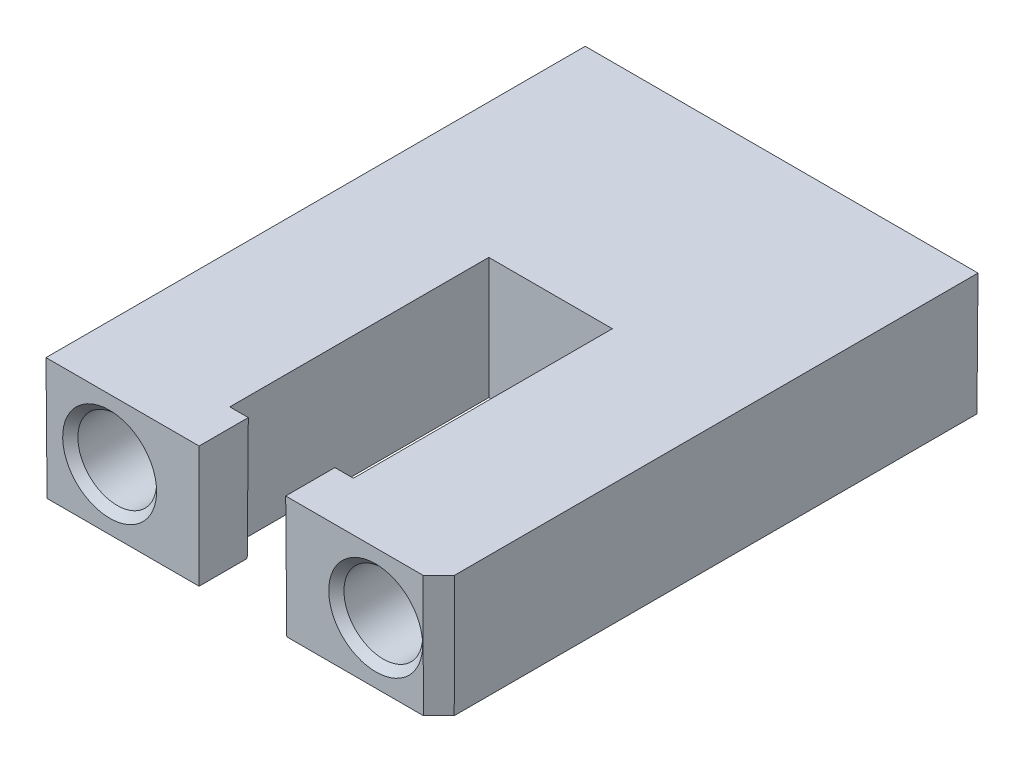
from build123d import *

# Parameters (mm, degrees)
SKETCH1_W                        = 25.3492
SKETCH1_H                        = 7.874
BOSS_EXTRUDE1_DEPTH              = 34.798
CUT_EXTRUDE1_DEPTH               = 8.874
F_97_0_0059_DIAMETER_HOLE1_D     = 5.08
F_97_0_0059_DIAMETER_HOLE1_DEPTH = 12.7
F_97_0_0059_DIAMETER_HOLE1_TIP   = 1.526185972
CHAMFER1_SIZE                    = 0.508
CHAMFER2_SIZE                    = 1.016
DRAFT1_ANGLE                     = -0.25


with BuildPart() as part:
    # Sketch1 → Boss-Extrude1 (new body)
    with BuildSketch(Plane.XY):
        Rectangle(SKETCH1_W, SKETCH1_H)
    extrude(amount=-BOSS_EXTRUDE1_DEPTH)

    # Sketch2 → Cut-Extrude1 (cut, through all)
    with BuildSketch(Plane(origin=(0, 3.937, 0), x_dir=(1, 0, 0), z_dir=(0, 1, 0))):
        Polygon((-2.794, 0), (-2.794, 3.175), (-3.9878, 3.175), (-3.9878, 19.8882), (3.9878, 19.8882), (3.9878, 3.175), (2.794, 3.175), (2.794, 0), align=None)
    extrude(amount=-CUT_EXTRUDE1_DEPTH, mode=Mode.SUBTRACT)

    # #97 (0.0059) Diameter Hole1
    with Locations(Plane.XY):
        with Locations((-8.5852, 0), (8.5852, 0)):
            Hole(F_97_0_0059_DIAMETER_HOLE1_D / 2, depth=F_97_0_0059_DIAMETER_HOLE1_DEPTH)
            with Locations((0, 0, -(F_97_0_0059_DIAMETER_HOLE1_DEPTH + F_97_0_0059_DIAMETER_HOLE1_TIP / 2))):  # 118° drill point
                Cone(0, F_97_0_0059_DIAMETER_HOLE1_D / 2, F_97_0_0059_DIAMETER_HOLE1_TIP, mode=Mode.SUBTRACT)

    # Chamfer1
    chamfer1_edges = [part.edges().sort_by_distance(p)[0] for p in [
        (11.1252, 0, 0),
        (-6.0452, 0, 0),
    ]]
    chamfer(chamfer1_edges, length=CHAMFER1_SIZE)

    # Chamfer2
    chamfer2_edges = [part.edges().sort_by_distance(p)[0] for p in [
        (12.6746, 0, 0),
    ]]
    chamfer(chamfer2_edges, length=CHAMFER2_SIZE)

    # Draft1
    draft1_faces = [part.faces().sort_by_distance(p)[0] for p in [
        (12.1666, 0, -0.508),
        (7.2263, 3.818433137, 0),
        (-5.410856764, 0, 0),
        (0, 0, -34.798),
        (-12.6746, 0, -17.399),
        (12.6746, 0, -17.907),
        (-3.3909, 0, -3.175),
        (3.3909, 0, -3.175),
        (2.794, 0, -1.5875),
        (3.9878, 0, -11.5316),
        (-2.794, 0, -1.5875),
        (0, 0, -19.8882),
        (-3.9878, 0, -11.5316),
    ]]
    draft(draft1_faces, Plane(origin=(-12.6746, 3.937, -34.798), x_dir=(1, 0, 0), z_dir=(0, 1, 0)), DRAFT1_ANGLE)


solid = part.part
